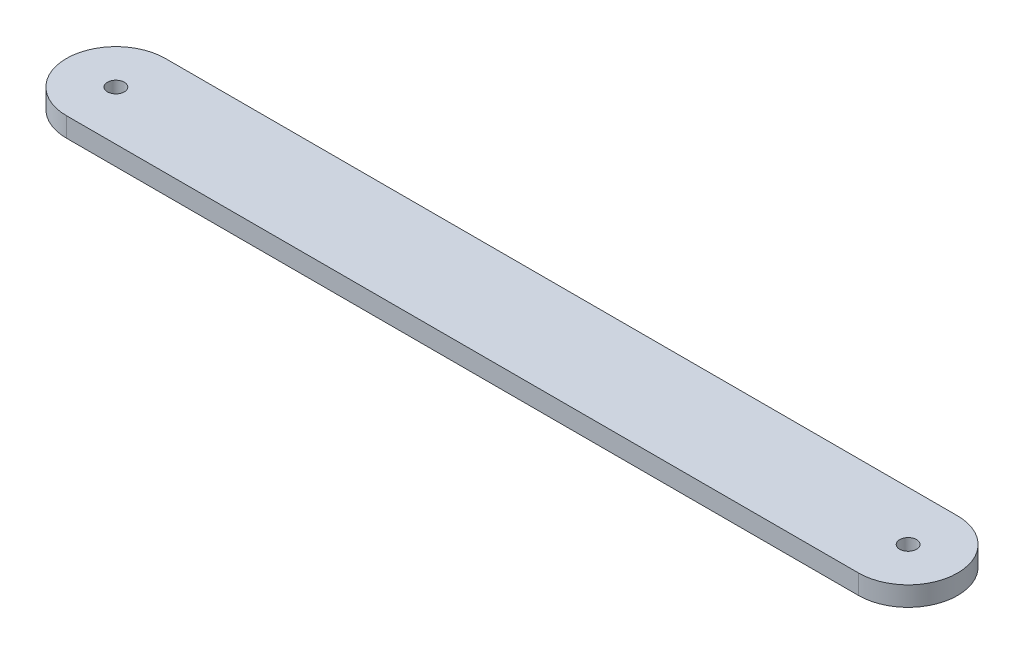
from build123d import *

# Parameters (mm, degrees)
SKETCH1_R           = 2.159
BOSS_EXTRUDE1_DEPTH = 5.0038


with BuildPart() as part:
    # Sketch1 → Boss-Extrude1 (new body)
    with BuildSketch(Plane(origin=(0, 0, 0), x_dir=(1, 0, 0), z_dir=(0, 1, 0))):
        with BuildLine():
            Line((-74.680553246, -7.673185862), (128.519446754, -7.673185862))
            ThreePointArc((128.519446754, -7.673185862), (141.219446754, -20.373185862), (128.519446754, -33.073185862))
            Line((128.519446754, -33.073185862), (-74.680553246, -33.073185862))
            ThreePointArc((-74.680553246, -33.073185862), (-87.380553246, -20.373185862), (-74.680553246, -7.673185862))
        make_face()
        with Locations((-74.680553246, -20.373185862)):
            Circle(SKETCH1_R, mode=Mode.SUBTRACT)
        with Locations((128.519446754, -20.373185862)):
            Circle(SKETCH1_R, mode=Mode.SUBTRACT)
    extrude(amount=BOSS_EXTRUDE1_DEPTH)


solid = part.part
